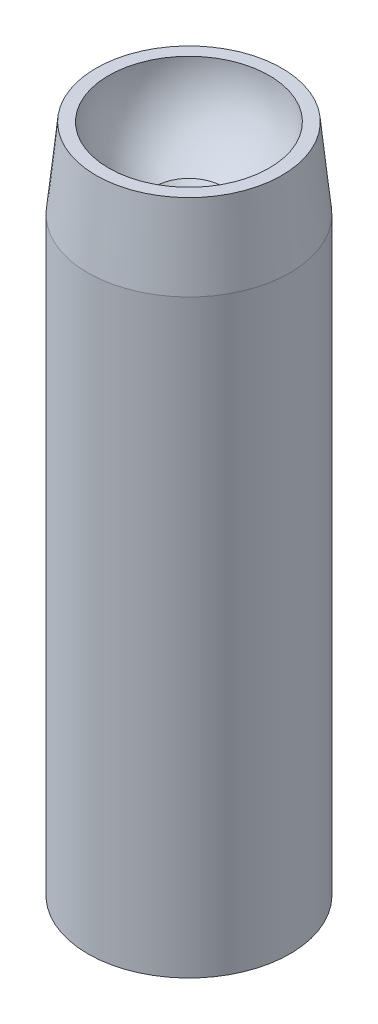
from build123d import *

# Parameters (mm, degrees)
SKETCH1_R           = 6
SKETCH1_R_2         = 5.2
BOSS_EXTRUDE1_DEPTH = 25
SKETCH2_R           = 6
SKETCH2_R_2         = 5
BOSS_EXTRUDE2_DEPTH = 10


with BuildPart() as part:
    # Sketch1 → Boss-Extrude1 (new body)
    with BuildSketch(Plane(origin=(0, 0, 0), x_dir=(1, 0, 0), z_dir=(0, 1, 0))):
        Circle(SKETCH1_R)
        Circle(SKETCH1_R_2, mode=Mode.SUBTRACT)
    extrude(amount=BOSS_EXTRUDE1_DEPTH)

    # Sketch2 → Boss-Extrude2 (add)
    with BuildSketch(Plane(origin=(0, 25, 0), x_dir=(1, 0, 0), z_dir=(0, 1, 0))):
        Circle(SKETCH2_R)
        Circle(SKETCH2_R_2, mode=Mode.SUBTRACT)
    extrude(amount=BOSS_EXTRUDE2_DEPTH)

    # Sketch3 → Revolve2 (revolve)
    with BuildSketch(Plane(origin=(0, 0, 0), x_dir=(0, 0, -1), z_dir=(1, 0, 0))):
        with BuildLine():
            Line((-6, 35), (-2, 35))
            Line((-2, 35), (-1.559699238, 35))
            Line((-1.559699238, 35), (-2, 35.440300762))
            ThreePointArc((-2, 35.440300762), (-4.012879655, 37.197699204), (-4.7625, 39.7625))
            Line((-4.7625, 39.7625), (-5.5125, 39.7625))
            Line((-5.5125, 39.7625), (-6, 35))
        make_face()
    revolve(axis=Axis((0, 33.973403882, 0), (0, -1, 0)))


solid = part.part
